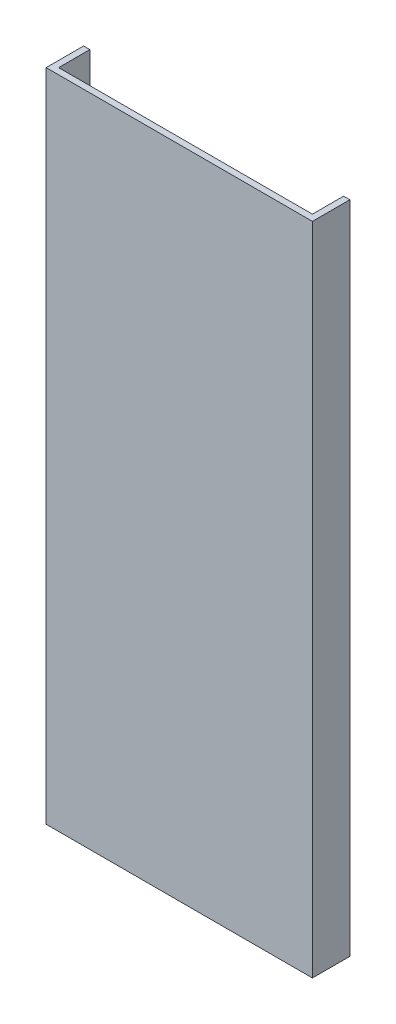
from build123d import *

# Parameters (mm, degrees)
SKETCH1_W           = 128
SKETCH1_H           = 315
BOSS_EXTRUDE1_DEPTH = 3
SKETCH2_W           = 3
SKETCH2_H           = 312
SKETCH2_H_2         = 3
SKETCH2_W_2         = 122
BOSS_EXTRUDE3_DEPTH = 15


with BuildPart() as part:
    # Sketch1 → Boss-Extrude1 (new body)
    with BuildSketch(Plane.XY):
        Rectangle(SKETCH1_W, SKETCH1_H)
    extrude(amount=BOSS_EXTRUDE1_DEPTH)

    # Sketch2 → Boss-Extrude3 (add)
    with BuildSketch(Plane(origin=(0, 0, 0), x_dir=(-1, 0, 0), z_dir=(0, 0, -1))):
        with Locations((-62.5, 1.5)):
            Rectangle(SKETCH2_W, SKETCH2_H)
        with Locations((-62.5, -156)):
            Rectangle(SKETCH2_W, SKETCH2_H_2)
        with Locations((0, -156)):
            Rectangle(SKETCH2_W_2, SKETCH2_H_2)
        with Locations((62.5, 1.5)):
            Rectangle(SKETCH2_W, SKETCH2_H)
        with Locations((62.5, -156)):
            Rectangle(SKETCH2_W, SKETCH2_H_2)
    extrude(amount=BOSS_EXTRUDE3_DEPTH)


solid = part.part
